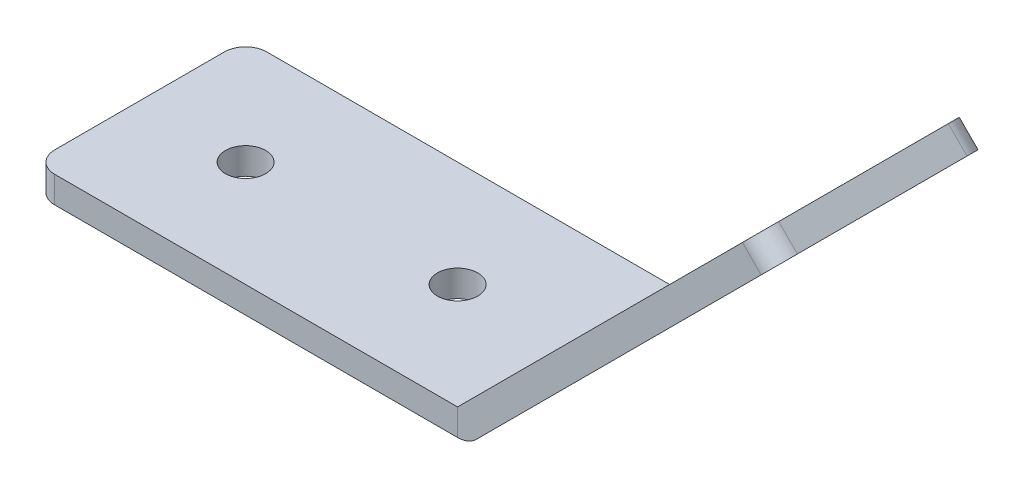
from build123d import *

# Parameters (mm, degrees)
SKETCH1_W           = 50.8
SKETCH1_H           = 25.4
BOSS_EXTRUDE1_DEPTH = 3.175
BOSS_EXTRUDE2_DEPTH = 25.4
SKETCH4_R           = 2.413
CUT_EXTRUDE1_DEPTH  = 3.175
SKETCH5_R           = 2.413
CUT_EXTRUDE2_DEPTH  = 3.175
FILLET1_R           = 2.54
FILLET2_R           = 2.54


with BuildPart() as part:
    # Sketch1 → Boss-Extrude1 (new body)
    with BuildSketch(Plane(origin=(0, 0, 0), x_dir=(1, 0, 0), z_dir=(0, 1, 0))):
        with Locations((25.4, -12.7)):
            Rectangle(SKETCH1_W, SKETCH1_H)
    extrude(amount=BOSS_EXTRUDE1_DEPTH)

    # Sketch4 → Cut-Extrude1 (cut)
    with BuildSketch(Plane(origin=(0, 3.175, 0), x_dir=(1, 0, 0), z_dir=(0, 1, 0))):
        with Locations((38.1, -12.7)):
            Circle(SKETCH4_R)
        with Locations((12.7, -12.7)):
            Circle(SKETCH4_R)
    extrude(amount=-CUT_EXTRUDE1_DEPTH, mode=Mode.SUBTRACT)

    # Fillet2
    fillet2_edges = [part.edges().sort_by_distance(p)[0] for p in [
        (0, 1.5875, 0),
        (0, 1.5875, 25.4),
    ]]
    fillet(fillet2_edges, radius=FILLET2_R)


with BuildPart() as body_2:
    # Sketch2 → Boss-Extrude2 (new body)
    with BuildSketch(Plane.XY.offset(25.4)):
        with BuildLine():
            Line((50.8, 3.175), (86.721024484, 39.096024484))
            Line((86.721024484, 39.096024484), (88.966088515, 36.850960454))
            Line((88.966088515, 36.850960454), (53.04506403, 0.92993597))
            ThreePointArc((53.04506403, 0.92993597), (52.015019898, 0.241682484), (50.8, 0))
            Line((50.8, 0), (50.8, 3.175))
        make_face()
    extrude(amount=-BOSS_EXTRUDE2_DEPTH)

    # Sketch5 → Cut-Extrude2 (cut)
    with BuildSketch(Plane(origin=(23.8125, -23.8125, 0), x_dir=(0, 0, 1), z_dir=(-0.707106781, 0.707106781, 0))):
        with Locations((12.7, 50.866088515)):
            Circle(SKETCH5_R)
        with Locations((12.7, 76.266088515)):
            Circle(SKETCH5_R)
    extrude(amount=-CUT_EXTRUDE2_DEPTH, mode=Mode.SUBTRACT)

    # Fillet1
    fillet1_edges = [body_2.edges().sort_by_distance(p)[0] for p in [
        (87.843556499, 37.973492469, 0),
        (87.843556499, 37.973492469, 25.4),
    ]]
    fillet(fillet1_edges, radius=FILLET1_R)


solid = Compound([part.part, body_2.part])
